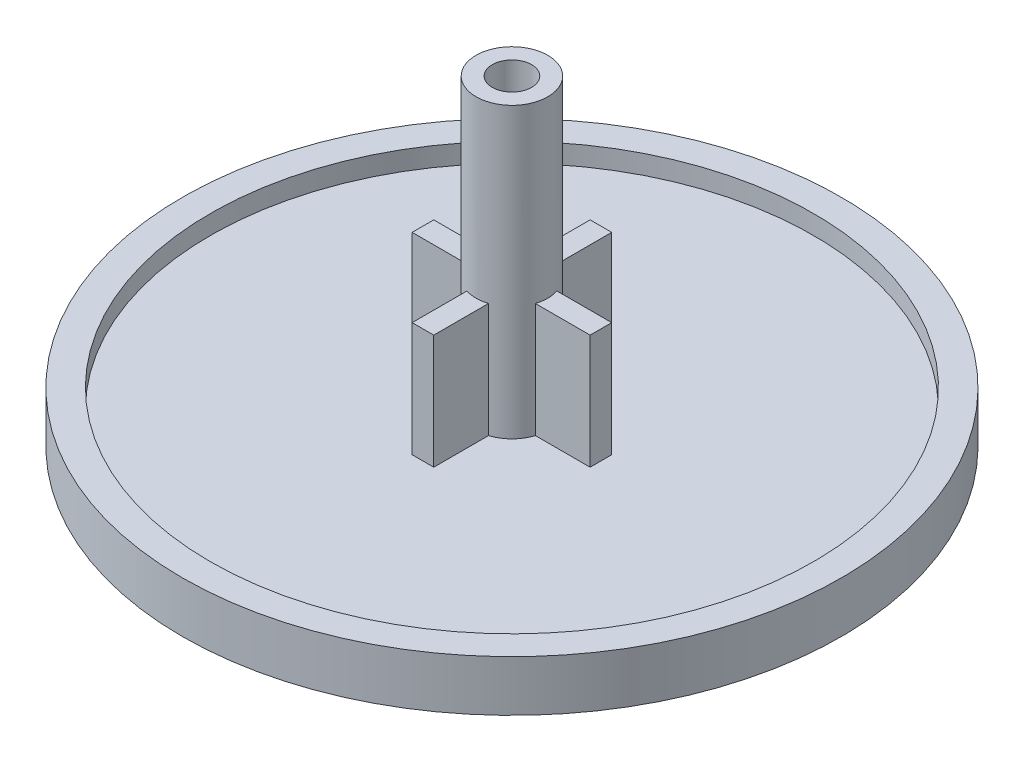
from build123d import *

# Parameters (mm, degrees)
SKETCH1_R           = 13.1699
BOSS_EXTRUDE1_DEPTH = 1.27
SKETCH2_R           = 13.1699
SKETCH2_R_2         = 12.0523
BOSS_EXTRUDE2_DEPTH = 0.762
SKETCH3_R           = 1.4351
BOSS_EXTRUDE3_DEPTH = 11.5443
SKETCH6_W           = 7.112
SKETCH6_H           = 5.842
BOSS_EXTRUDE4_DEPTH = 0.4318
SKETCH7_W           = 7.112
SKETCH7_H           = 5.842
BOSS_EXTRUDE5_DEPTH = 0.4318
SKETCH4_R           = 0.7874
CUT_EXTRUDE1_DEPTH  = 11.5443


with BuildPart() as part:
    # Sketch1 → Boss-Extrude1 (new body)
    with BuildSketch(Plane(origin=(0, 0, 0), x_dir=(1, 0, 0), z_dir=(0, 1, 0))):
        Circle(SKETCH1_R)
    extrude(amount=BOSS_EXTRUDE1_DEPTH)

    # Sketch2 → Boss-Extrude2 (add)
    with BuildSketch(Plane(origin=(0, 1.27, 0), x_dir=(1, 0, 0), z_dir=(0, 1, 0))):
        Circle(SKETCH2_R)
        Circle(SKETCH2_R_2, mode=Mode.SUBTRACT)
    extrude(amount=BOSS_EXTRUDE2_DEPTH)

    # Sketch3 → Boss-Extrude3 (add)
    with BuildSketch(Plane(origin=(0, 1.27, 0), x_dir=(1, 0, 0), z_dir=(0, 1, 0))):
        Circle(SKETCH3_R)
    extrude(amount=BOSS_EXTRUDE3_DEPTH)

    # Sketch6 → Boss-Extrude4 (add, symmetric)
    with BuildSketch(Plane.XY):
        with Locations((0, 2.921)):
            Rectangle(SKETCH6_W, SKETCH6_H)
    extrude(amount=BOSS_EXTRUDE4_DEPTH, both=True)

    # Sketch7 → Boss-Extrude5 (add, symmetric)
    with BuildSketch(Plane(origin=(0, 0, 0), x_dir=(0, 0, -1), z_dir=(1, 0, 0))):
        with Locations((0, 2.921)):
            Rectangle(SKETCH7_W, SKETCH7_H)
    extrude(amount=BOSS_EXTRUDE5_DEPTH, both=True)

    # Sketch4 → Cut-Extrude1 (cut)
    with BuildSketch(Plane(origin=(0, 12.8143, 0), x_dir=(1, 0, 0), z_dir=(0, 1, 0))):
        Circle(SKETCH4_R)
    extrude(amount=-CUT_EXTRUDE1_DEPTH, mode=Mode.SUBTRACT)


solid = part.part
